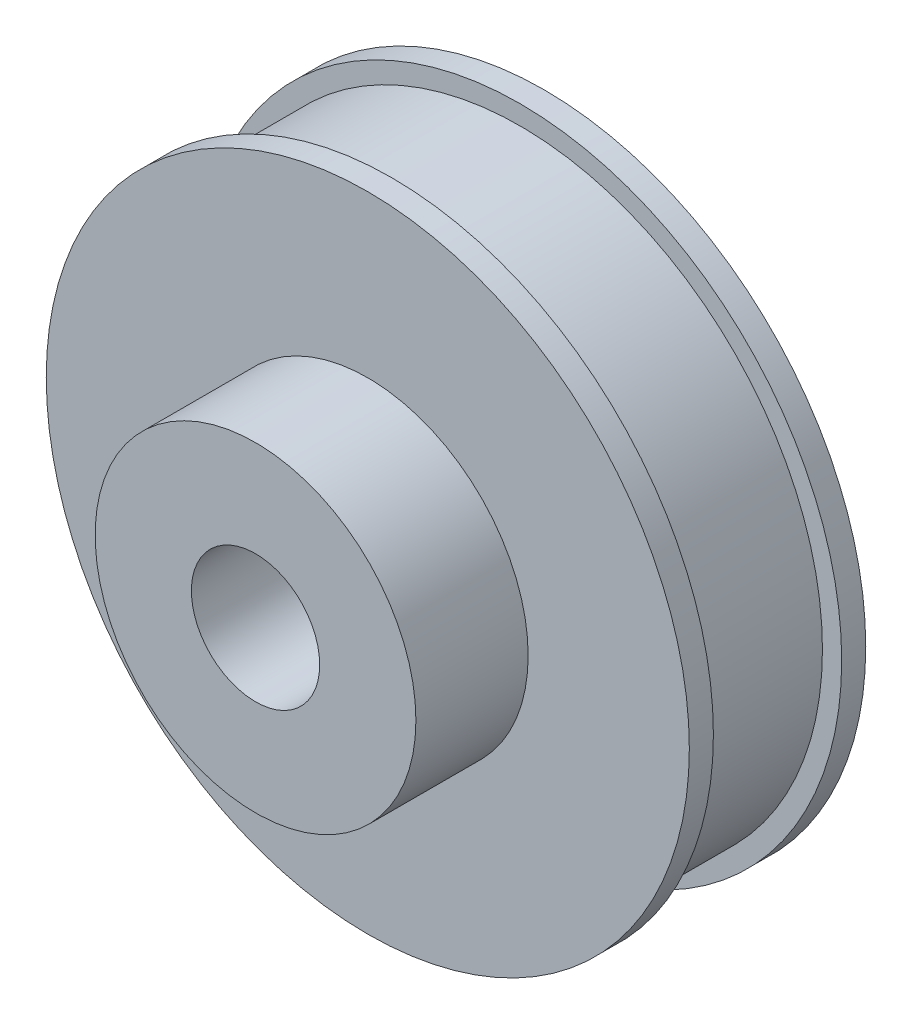
from build123d import *

# Parameters (mm, degrees)
SKETCH1_R           = 18.85
SKETCH1_R_2         = 4
BOSS_EXTRUDE1_DEPTH = 11
SKETCH1_3_R         = 20.05
SKETCH1_3_R_2       = 18.85
BOSS_EXTRUDE2_DEPTH = 1.5
BOSS_EXTRUDE3_START = 9.5
SKETCH1_4_R         = 20.05
SKETCH1_4_R_2       = 18.85
BOSS_EXTRUDE3_DEPTH = 1.5
SKETCH1_5_R         = 10
SKETCH1_5_R_2       = 4
BOSS_EXTRUDE4_DEPTH = 18


with BuildPart() as part:
    # Sketch1 → Boss-Extrude1 (new body)
    with BuildSketch(Plane.XY):
        Circle(SKETCH1_R)
        Circle(SKETCH1_R_2, mode=Mode.SUBTRACT)
    extrude(amount=BOSS_EXTRUDE1_DEPTH)

    # Sketch1_3 → Boss-Extrude2 (add)
    with BuildSketch(Plane.XY):
        Circle(SKETCH1_3_R)
        Circle(SKETCH1_3_R_2, mode=Mode.SUBTRACT)
    extrude(amount=BOSS_EXTRUDE2_DEPTH)

    # Sketch1_4 → Boss-Extrude3 (add)
    with BuildSketch(Plane.XY.offset(BOSS_EXTRUDE3_START)):
        Circle(SKETCH1_4_R)
        Circle(SKETCH1_4_R_2, mode=Mode.SUBTRACT)
    extrude(amount=BOSS_EXTRUDE3_DEPTH)

    # Sketch1_5 → Boss-Extrude4 (add)
    with BuildSketch(Plane.XY):
        Circle(SKETCH1_5_R)
        Circle(SKETCH1_5_R_2, mode=Mode.SUBTRACT)
    extrude(amount=BOSS_EXTRUDE4_DEPTH)


solid = part.part
